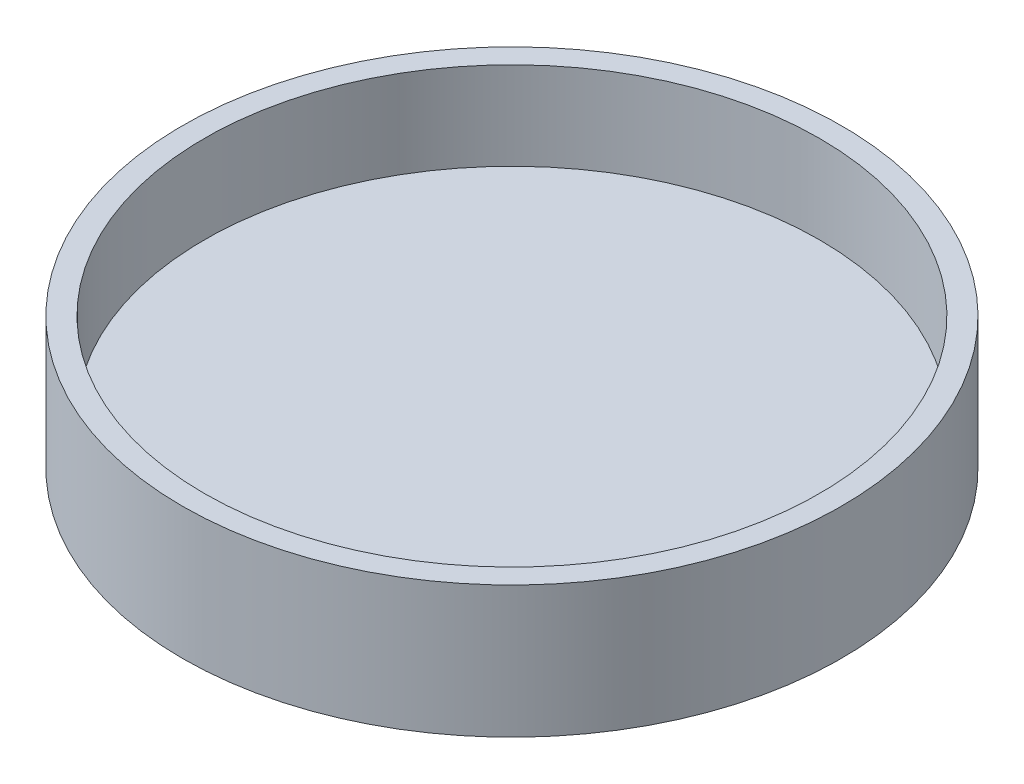
from build123d import *

# Parameters (mm, degrees)
SKETCH1_R           = 190.5
BOSS_EXTRUDE1_DEPTH = 25.4
SKETCH2_R           = 190.5
SKETCH2_R_2         = 177.8
BOSS_EXTRUDE2_DEPTH = 50.8


with BuildPart() as part:
    # Sketch1 → Boss-Extrude1 (new body)
    with BuildSketch(Plane(origin=(0, 0, 0), x_dir=(1, 0, 0), z_dir=(0, 1, 0))):
        Circle(SKETCH1_R)
    extrude(amount=BOSS_EXTRUDE1_DEPTH)

    # Sketch2 → Boss-Extrude2 (add)
    with BuildSketch(Plane(origin=(0, 25.4, 0), x_dir=(1, 0, 0), z_dir=(0, 1, 0))):
        Circle(SKETCH2_R)
        Circle(SKETCH2_R_2, mode=Mode.SUBTRACT)
    extrude(amount=BOSS_EXTRUDE2_DEPTH)


solid = part.part
